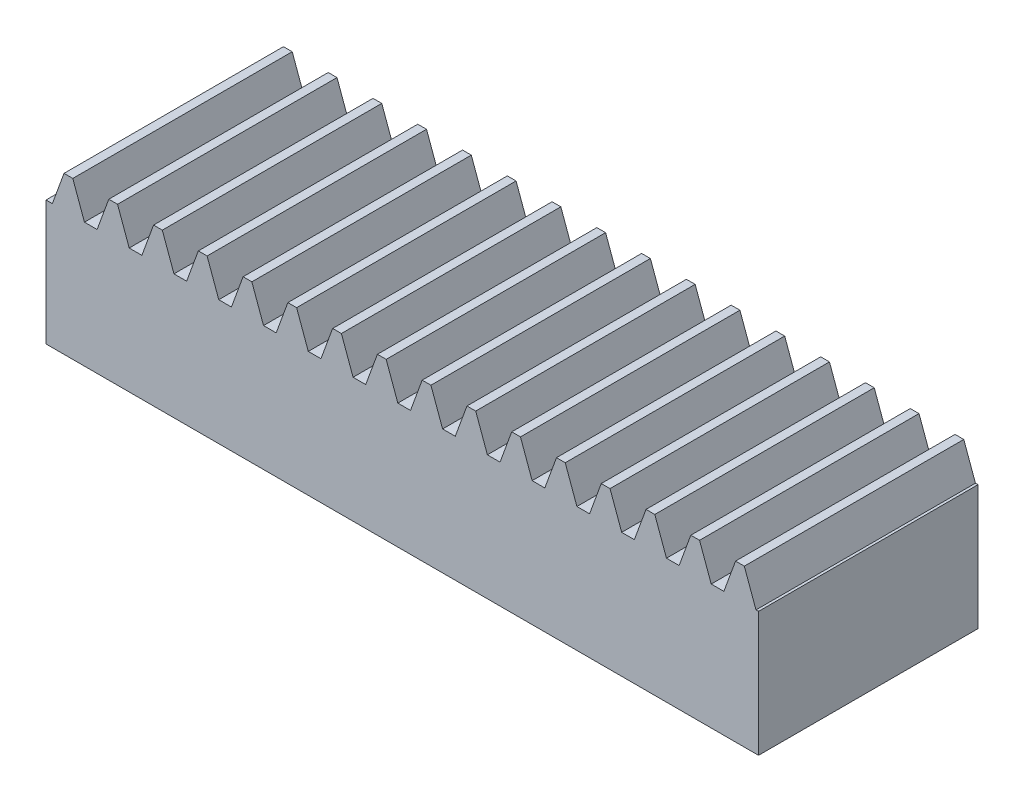
from build123d import *

# Parameters (mm, degrees)
BLANKSKE_W        = 25
BLANKSKE_H        = 5.5
BLANK_DEPTH       = 7.7
TOOTHCUTSIM_DEPTH = 27.730881018
TEETHCUTS_COUNT   = 17
TEETHCUTS_PITCH   = 1.570796325


with BuildPart() as part:
    # BlankSke → Blank (new body)
    with BuildSketch(Plane.XY):
        with Locations((12.5, 2.75)):
            Rectangle(BLANKSKE_W, BLANKSKE_H)
    extrude(amount=-BLANK_DEPTH)

    # TooCutSkeSim → ToothCutSim (cut, through all)
    with BuildSketch(Plane.XY):
        Polygon((0.222217685, 4.375), (-0.222217685, 4.375), (-0.640929042, 5.5254), (0.640929042, 5.5254), align=None)
    toothcutsim = extrude(amount=-TOOTHCUTSIM_DEPTH, mode=Mode.SUBTRACT)

    # TeethCuts: ToothCutSim ×17
    with Locations(*[(i * TEETHCUTS_PITCH, 0, 0) for i in range(1, TEETHCUTS_COUNT)]):
        add(toothcutsim, mode=Mode.SUBTRACT)


solid = part.part
